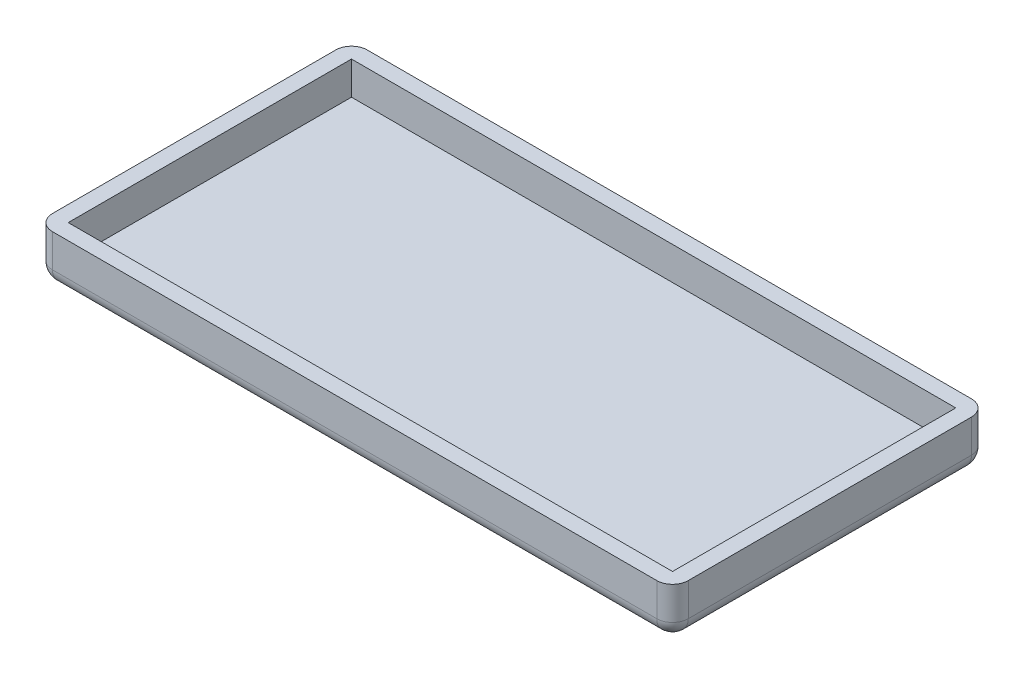
from build123d import *

# Parameters (mm, degrees)
ESQUISSE1_W        = 40.4
ESQUISSE1_H        = 20
BOSS_EXTRU_1_DEPTH = 1
ESQUISSE2_W        = 40.4
ESQUISSE2_H        = 20
ESQUISSE2_W_2      = 38.4
ESQUISSE2_H_2      = 18
BOSS_EXTRU_2_DEPTH = 2.1
CONG_1_R           = 1


with BuildPart() as part:
    # Esquisse1 → Boss.-Extru.1 (new body)
    with BuildSketch(Plane(origin=(0, 0, 0), x_dir=(1, 0, 0), z_dir=(0, 1, 0))):
        with Locations((-5.381395349, 0)):
            Rectangle(ESQUISSE1_W, ESQUISSE1_H)
    extrude(amount=BOSS_EXTRU_1_DEPTH)

    # Esquisse2 → Boss.-Extru.2 (add)
    with BuildSketch(Plane(origin=(0, 1, 0), x_dir=(1, 0, 0), z_dir=(0, 1, 0))):
        with Locations((-5.381395349, 0)):
            Rectangle(ESQUISSE2_W, ESQUISSE2_H)
        with Locations((-5.381395349, 0)):
            Rectangle(ESQUISSE2_W_2, ESQUISSE2_H_2, mode=Mode.SUBTRACT)
    extrude(amount=BOSS_EXTRU_2_DEPTH)

    # Congé1
    cong_1_edges = [part.edges().sort_by_distance(p)[0] for p in [
        (-5.381395349, 0, -10),
        (14.818604651, 0, 0),
        (-5.381395349, 0, 10),
        (-25.581395349, 0, 0),
        (-25.581395349, 1.55, -10),
        (14.818604651, 1.55, -10),
        (14.818604651, 1.55, 10),
        (-25.581395349, 1.55, 10),
    ]]
    fillet(cong_1_edges, radius=CONG_1_R)


solid = part.part
